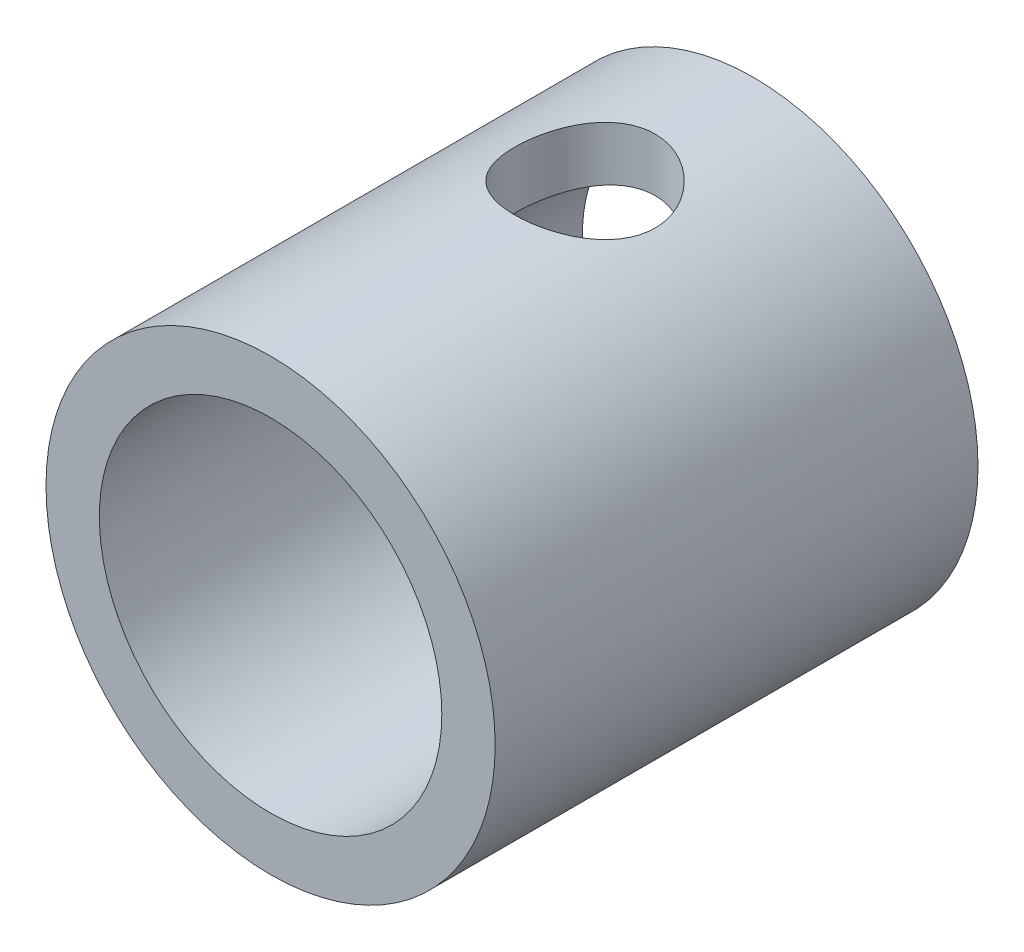
from build123d import *

# Parameters (mm, degrees)
SKIZZE2_R                       = 4
SKIZZE2_R_2                     = 3.05
AUFSATZ_LINEAR_AUSTRAGEN1_DEPTH = 4.3
SKIZZE3_R                       = 1.25
SCHNITT_LINEAR_AUSTRAGEN1_DEPTH = 5


with BuildPart() as part:
    # Skizze2 → Aufsatz-Linear austragen1 (new body, symmetric)
    with BuildSketch(Plane.XY):
        Circle(SKIZZE2_R)
        Circle(SKIZZE2_R_2, mode=Mode.SUBTRACT)
    extrude(amount=AUFSATZ_LINEAR_AUSTRAGEN1_DEPTH, both=True)

    # Skizze3 → Schnitt-Linear austragen1 (cut, through all)
    with BuildSketch(Plane(origin=(0, 0, 0), x_dir=(1, 0, 0), z_dir=(0, 1, 0))):
        with Locations((0, 1.3)):
            Circle(SKIZZE3_R)
    extrude(amount=SCHNITT_LINEAR_AUSTRAGEN1_DEPTH, mode=Mode.SUBTRACT)


solid = part.part
